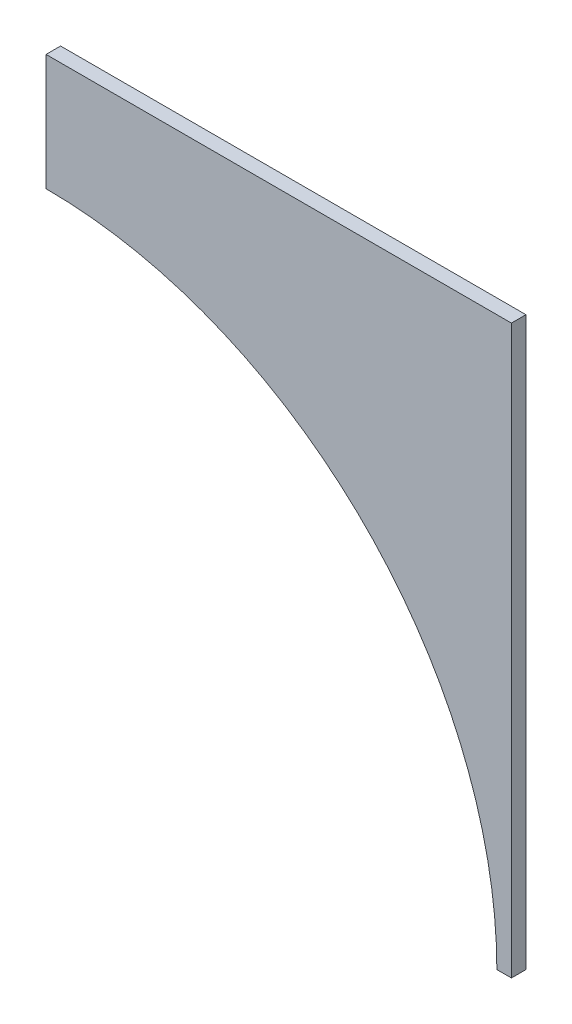
from build123d import *

# Parameters (mm, degrees)
BOSS_EXTRUDE1_DEPTH = 3.175


with BuildPart() as part:
    # Sketch1 → Boss-Extrude1 (new body)
    with BuildSketch(Plane.XY):
        with BuildLine():
            Line((-71.953806461, 91.039951247), (29.646193539, 91.039951247))
            Line((29.646193539, 91.039951247), (29.646193539, -32.785048753))
            Line((29.646193539, -32.785048753), (26.471193539, -32.785048753))
            ThreePointArc((26.471193539, -32.785048753), (-2.356821523, 36.811936186), (-71.953806461, 65.639951247))
            Line((-71.953806461, 65.639951247), (-71.953806461, 91.039951247))
        make_face()
    extrude(amount=-BOSS_EXTRUDE1_DEPTH)


solid = part.part
